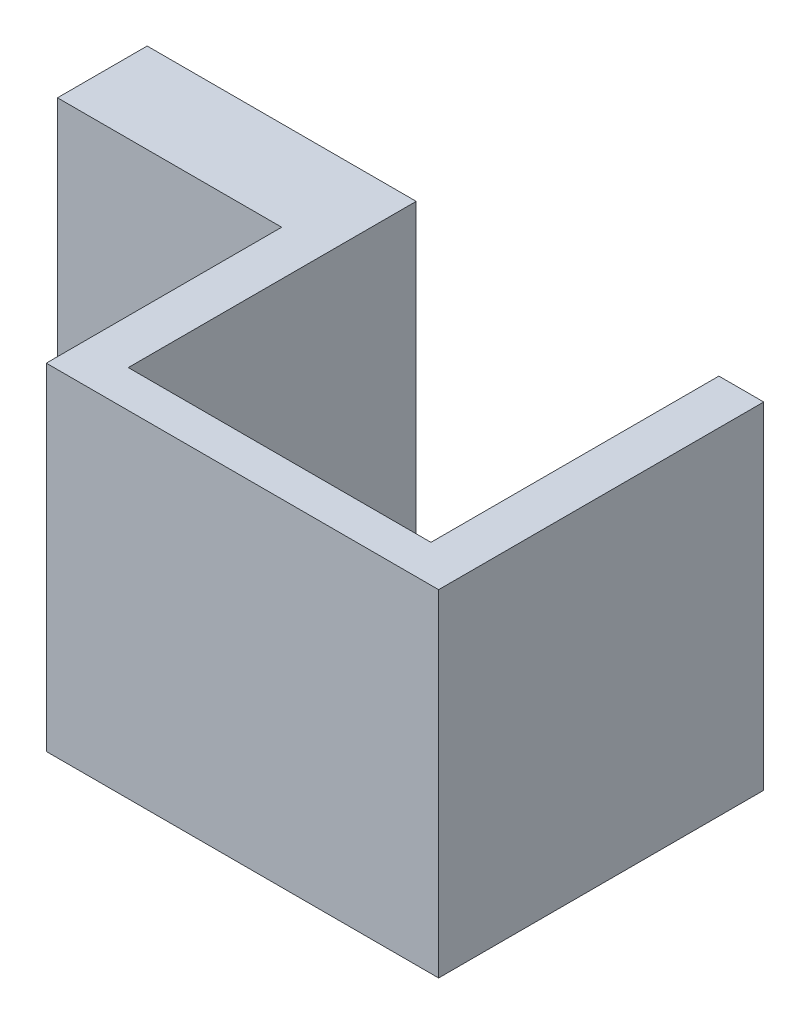
from build123d import *

# Parameters (mm, degrees)
CROQUIS1_W              = 10
CROQUIS1_H              = 4
SALIENTE_EXTRUIR1_DEPTH = 15
CROQUIS2_R              = 1.5
CORTAR_EXTRUIR1_DEPTH   = 15


with BuildPart() as part:
    # Croquis1 → Saliente-Extruir1 (new body)
    with BuildSketch(Plane(origin=(0, 0, 0), x_dir=(1, 0, 0), z_dir=(0, 1, 0))):
        Polygon((-8.75, 3.25), (-8.75, -7.25), (8.75, -7.25), (8.75, 7.25), (6.75, 7.25), (6.75, -5.592857143), (-6.75, -5.592857143), (-6.75, 7.25), (-8.75, 7.25), align=None)
        with Locations((-13.75, 5.25)):
            Rectangle(CROQUIS1_W, CROQUIS1_H)
    extrude(amount=SALIENTE_EXTRUIR1_DEPTH)

    # Croquis2 → Cortar-Extruir1 (cut)
    with BuildSketch(Plane.XY.offset(-3.25)):
        with Locations((-13.75, 7.5)):
            Circle(CROQUIS2_R)
    extrude(amount=-CORTAR_EXTRUIR1_DEPTH, mode=Mode.SUBTRACT)


solid = part.part
